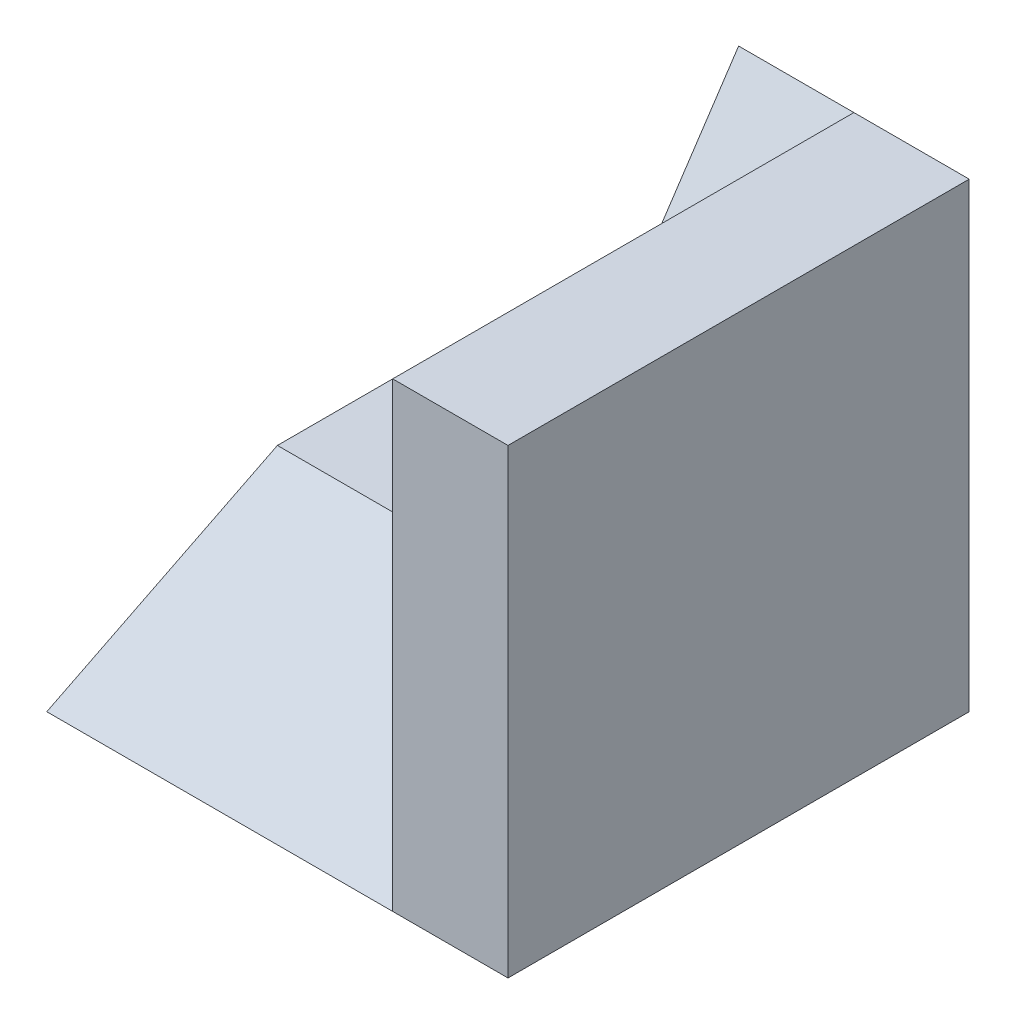
from build123d import *

# Parameters (mm, degrees)
SKETCH1_W           = 4
SKETCH1_H           = 4
BOSS_EXTRUDE1_DEPTH = 4
CUT_EXTRUDE1_DEPTH  = 3
SKETCH3_W           = 2
SKETCH3_H           = 2
CUT_EXTRUDE2_DEPTH  = 3


with BuildPart() as part:
    # Sketch1 → Boss-Extrude1 (new body)
    with BuildSketch(Plane(origin=(0, 0, 0), x_dir=(1, 0, 0), z_dir=(0, 1, 0))):
        Rectangle(SKETCH1_W, SKETCH1_H)
    extrude(amount=BOSS_EXTRUDE1_DEPTH)

    # Sketch2 → Cut-Extrude1 (cut)
    with BuildSketch(Plane.ZY.offset(2)):
        Polygon((-2, 4), (0, 1), (2, 0), (2, 4), align=None)
    extrude(amount=-CUT_EXTRUDE1_DEPTH, mode=Mode.SUBTRACT)

    # Sketch3 → Cut-Extrude2 (cut)
    with BuildSketch(Plane(origin=(0, 4, 0), x_dir=(1, 0, 0), z_dir=(0, 1, 0))):
        with Locations((-1, 1)):
            Rectangle(SKETCH3_W, SKETCH3_H)
    extrude(amount=-CUT_EXTRUDE2_DEPTH, mode=Mode.SUBTRACT)


solid = part.part
